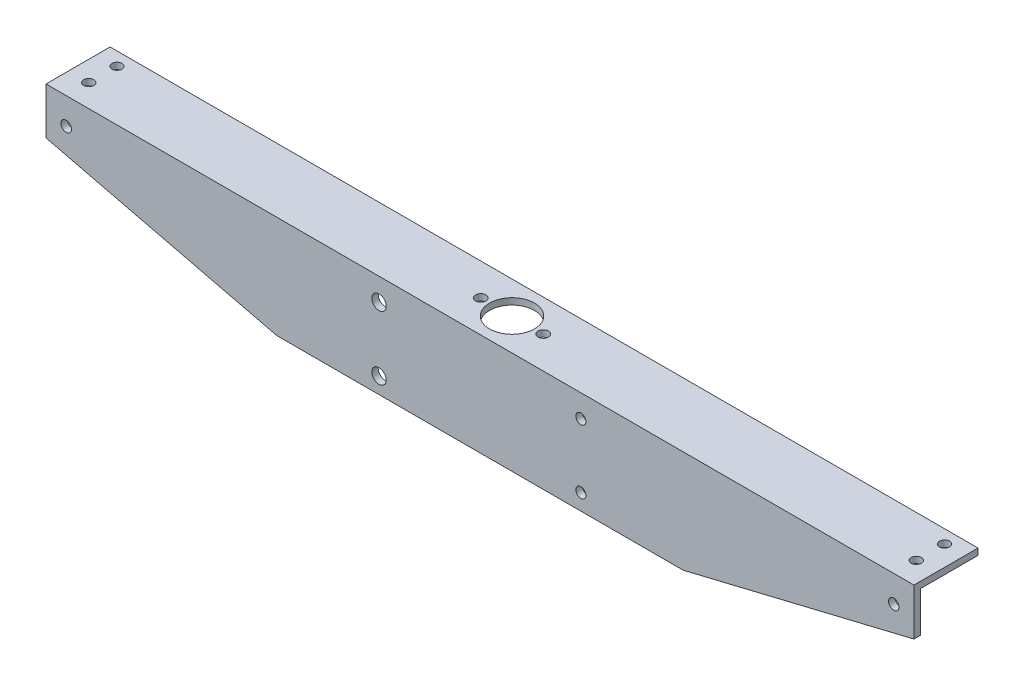
from build123d import *

# Parameters (mm, degrees)
BOSS_EXTRUDE1_DEPTH = 215
SKETCH2_R           = 2.5
SKETCH2_R_2         = 3.57
CUT_EXTRUDE1_DEPTH  = 4.175
CUT_EXTRUDE2_DEPTH  = 3.175
SKETCH4_R           = 2.5
CUT_EXTRUDE3_DEPTH  = 3.175
CUT_EXTRUDE4_REACH  = 5.175
SKETCH5_R           = 11.1125
SKETCH6_R           = 2.6
CUT_EXTRUDE5_DEPTH  = 3.175
SKETCH7_R           = 2.6
CUT_EXTRUDE6_DEPTH  = 3.175


with BuildPart() as part:
    # Sketch1 → Boss-Extrude1 (new body, symmetric)
    with BuildSketch(Plane(origin=(0, 0, 0), x_dir=(0, 0, -1), z_dir=(1, 0, 0))):
        Polygon((0, 0), (31.75, 0), (31.75, -3.175), (3.175, -3.175), (3.175, -50.8), (0, -50.8), align=None)
    extrude(amount=BOSS_EXTRUDE1_DEPTH, both=True)

    # Sketch2 → Cut-Extrude1 (cut, through all)
    with BuildSketch(Plane(origin=(0, 0, -3.175), x_dir=(-1, 0, 0), z_dir=(0, 0, -1))):
        with Locations((-50, -11.175)):
            Circle(SKETCH2_R)
        with Locations((50, -11.175)):
            Circle(SKETCH2_R_2)
        with Locations((50, -42.8)):
            Circle(SKETCH2_R_2)
        with Locations((-50, -42.8)):
            Circle(SKETCH2_R)
    extrude(amount=-CUT_EXTRUDE1_DEPTH, mode=Mode.SUBTRACT)

    # Sketch3 → Cut-Extrude2 (cut)
    with BuildSketch(Plane(origin=(0, 0, -3.175), x_dir=(-1, 0, 0), z_dir=(0, 0, -1))):
        Polygon((215, -50.8), (100.7, -50.8), (215, -23.175), align=None)
        Polygon((-215, -23.175), (-215, -50.8), (-100.7, -50.8), align=None)
    extrude(amount=-CUT_EXTRUDE2_DEPTH, mode=Mode.SUBTRACT)

    # Sketch4 → Cut-Extrude3 (cut)
    with BuildSketch(Plane(origin=(0, 0, 0), x_dir=(1, 0, 0), z_dir=(0, 1, 0))):
        with Locations((-205, 11.176)):
            Circle(SKETCH4_R)
        with Locations((-205, 25.176)):
            Circle(SKETCH4_R)
        with Locations((205, 25.176)):
            Circle(SKETCH4_R)
        with Locations((205, 11.176)):
            Circle(SKETCH4_R)
    extrude(amount=-CUT_EXTRUDE3_DEPTH, mode=Mode.SUBTRACT)

    # Sketch5 → Cut-Extrude4 (cut, up to next)
    with BuildSketch(Plane.XZ.offset(3.175), mode=Mode.PRIVATE) as cut_extrude4_sk1:
        with Locations((0, -15.875)):
            Circle(SKETCH5_R)
    cut_extrude4_tool1 = extrude(cut_extrude4_sk1.sketch, amount=-CUT_EXTRUDE4_REACH, mode=Mode.PRIVATE) & part.part
    add(cut_extrude4_tool1.solids().sort_by_distance((0, -3.175, -15.875))[0], mode=Mode.SUBTRACT)

    # Sketch6 → Cut-Extrude5 (cut)
    with BuildSketch(Plane.XY):
        with Locations((205, -13.175000066)):
            Circle(SKETCH6_R)
        with Locations((-205, -13.175000066)):
            Circle(SKETCH6_R)
    extrude(amount=-CUT_EXTRUDE5_DEPTH, mode=Mode.SUBTRACT)

    # Sketch7 → Cut-Extrude6 (cut)
    with BuildSketch(Plane(origin=(0, 0, 0), x_dir=(1, 0, 0), z_dir=(0, 1, 0))):
        with Locations((15.5, 15.875)):
            Circle(SKETCH7_R)
        with Locations((-15.5, 15.875)):
            Circle(SKETCH7_R)
    extrude(amount=-CUT_EXTRUDE6_DEPTH, mode=Mode.SUBTRACT)


solid = part.part
